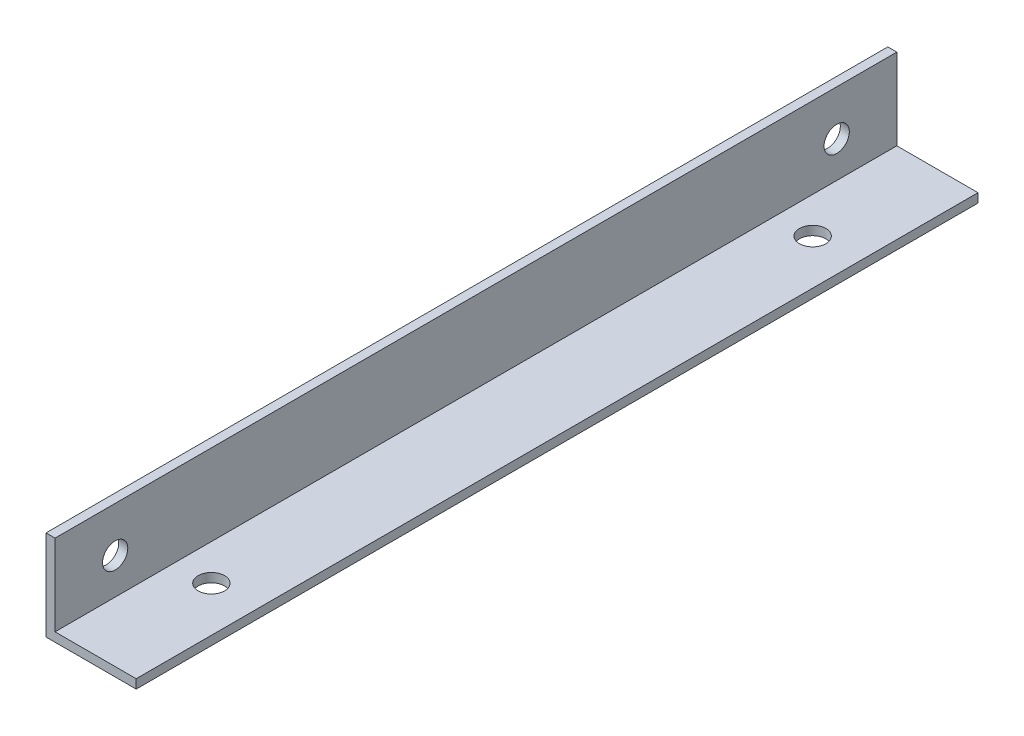
from build123d import *

# Parameters (mm, degrees)
EXTRUDE_1_DEPTH     = 140
SKETCH_2_R          = 2.1
CUT_EXTRUDE_1_DEPTH = 140
SKETCH_3_R          = 2.2
CUT_EXTRUDE_2_DEPTH = 140


with BuildPart() as part:
    # ｽｹｯﾁ1 → ﾎﾞｽ - 押し出し1 (new body)
    with BuildSketch(Plane.XY):
        Polygon((0, 0), (0, 15), (1.5, 15), (1.5, 1.5), (15, 1.5), (15, 0), align=None)
    extrude(amount=EXTRUDE_1_DEPTH)

    # ｽｹｯﾁ2 → ｶｯﾄ - 押し出し1 (cut)
    with BuildSketch(Plane.ZY):
        with Locations((130, 7.5)):
            Circle(SKETCH_2_R)
        with Locations((10, 7.5)):
            Circle(SKETCH_2_R)
    extrude(amount=-CUT_EXTRUDE_1_DEPTH, mode=Mode.SUBTRACT)

    # ｽｹｯﾁ3 → ｶｯﾄ - 押し出し2 (cut)
    with BuildSketch(Plane(origin=(0, 0, 0), x_dir=(-1, 0, 0), z_dir=(0, -1, 0))):
        with Locations((-7.5, -120)):
            Circle(SKETCH_3_R)
        with Locations((-7.5, -20)):
            Circle(SKETCH_3_R)
    extrude(amount=-CUT_EXTRUDE_2_DEPTH, mode=Mode.SUBTRACT)


solid = part.part
